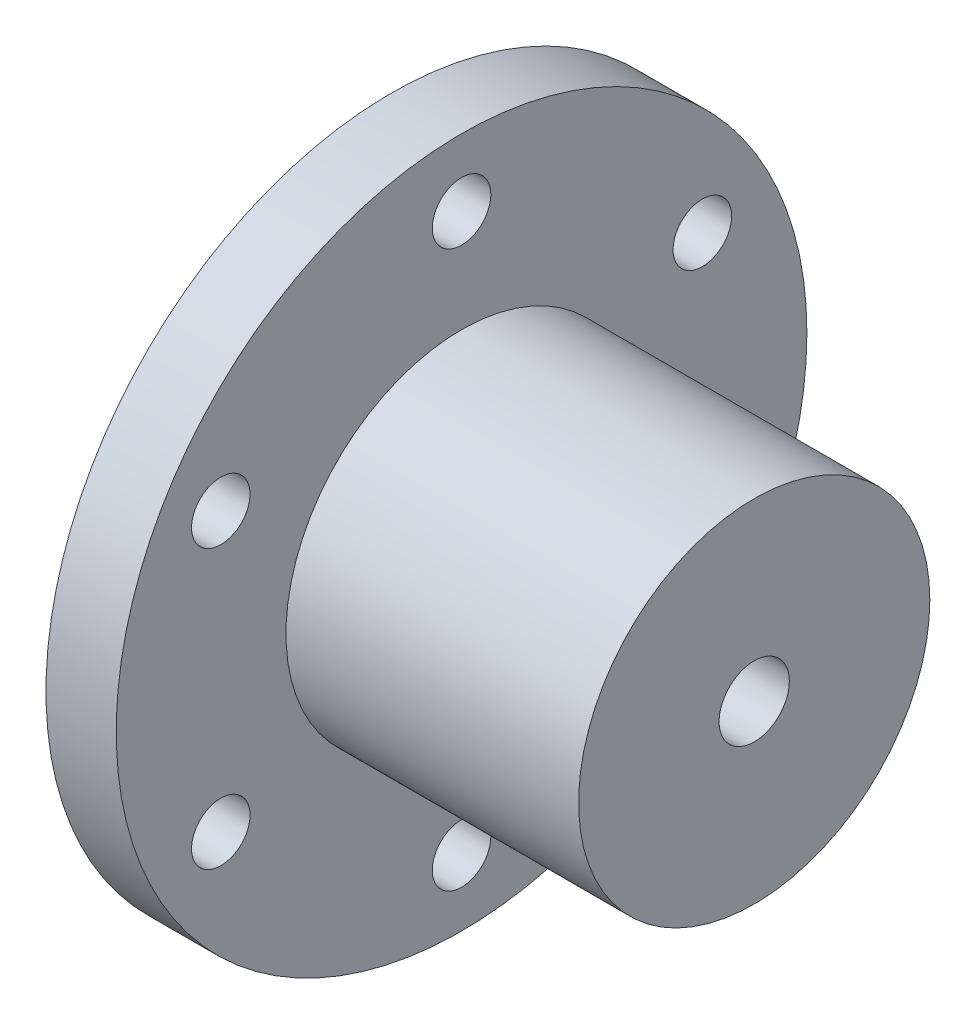
from build123d import *

# Parameters (mm, degrees)
SKETCH1_R           = 29.5
BOSS_EXTRUDE1_DEPTH = 6
SKETCH2_R           = 15
BOSS_EXTRUDE2_DEPTH = 25
SKETCH3_R           = 3
CUT_EXTRUDE1_DEPTH  = 25
SKETCH4_R           = 2.5
CUT_EXTRUDE2_DEPTH  = 25


with BuildPart() as part:
    # Sketch1 → Boss-Extrude1 (new body)
    with BuildSketch(Plane(origin=(0, 0, 0), x_dir=(0, 0, -1), z_dir=(1, 0, 0))):
        Circle(SKETCH1_R)
    extrude(amount=BOSS_EXTRUDE1_DEPTH)

    # Sketch2 → Boss-Extrude2 (add)
    with BuildSketch(Plane(origin=(6, 0, 0), x_dir=(0, 0, -1), z_dir=(1, 0, 0))):
        Circle(SKETCH2_R)
    extrude(amount=BOSS_EXTRUDE2_DEPTH)

    # Sketch3 → Cut-Extrude1 (cut)
    with BuildSketch(Plane(origin=(31, 0, 0), x_dir=(0, 0, -1), z_dir=(1, 0, 0))):
        Circle(SKETCH3_R)
    extrude(amount=-CUT_EXTRUDE1_DEPTH, mode=Mode.SUBTRACT)

    # Sketch4 → Cut-Extrude2 (cut)
    with BuildSketch(Plane(origin=(6, 0, 0), x_dir=(0, 0, -1), z_dir=(1, 0, 0))):
        with Locations((0, 23.75)):
            Circle(SKETCH4_R)
        with Locations((20.56810334, 11.875)):
            Circle(SKETCH4_R)
        with Locations((20.56810334, -11.875)):
            Circle(SKETCH4_R)
        with Locations((0, -23.75)):
            Circle(SKETCH4_R)
        with Locations((-20.56810334, -11.875)):
            Circle(SKETCH4_R)
        with Locations((-20.56810334, 11.875)):
            Circle(SKETCH4_R)
    extrude(amount=-CUT_EXTRUDE2_DEPTH, mode=Mode.SUBTRACT)


solid = part.part
